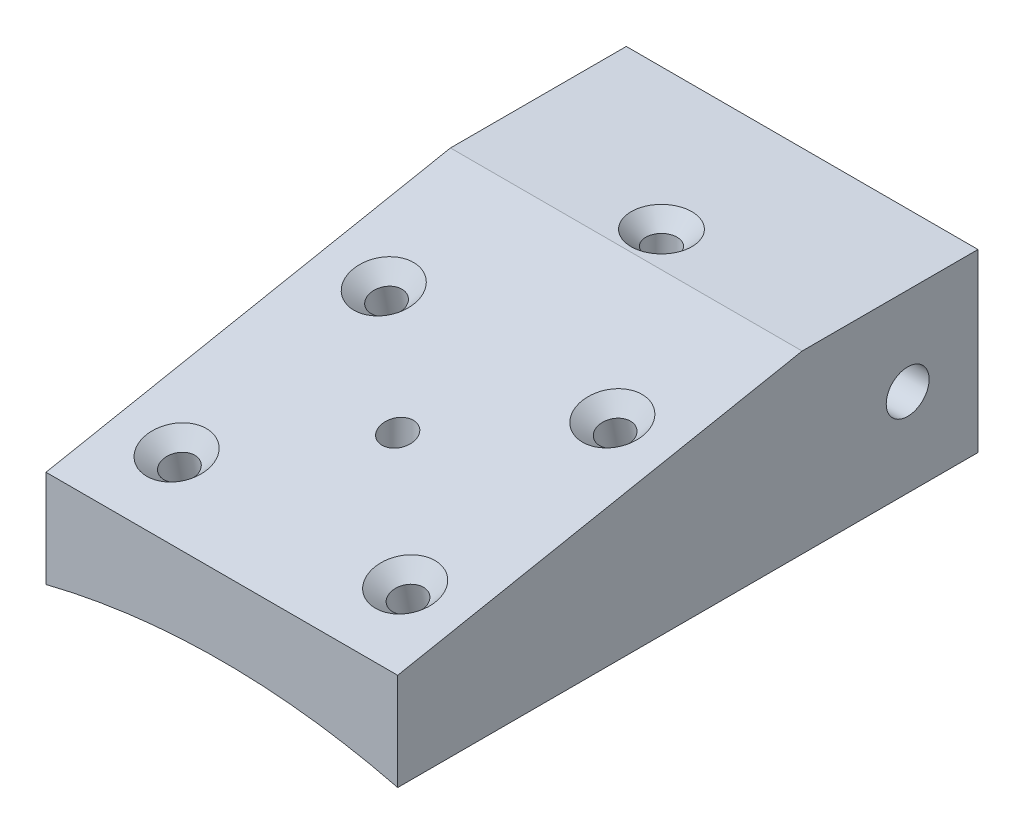
from build123d import *

# Parameters (mm, degrees)
BOSS_EXTRUDE1_DEPTH             = 11.5
F_2_56_TAPPED_HOLE3_D           = 1.778
F_2_56_TAPPED_HOLE3_CSINK_D     = 3.4544
F_2_56_TAPPED_HOLE3_CSINK_ANGLE = 90
CUT_EXTRUDE1_DEPTH              = 10
F_2_56_TAPPED_HOLE1_D           = 1.778
F_2_56_TAPPED_HOLE1_CSINK_D     = 3.4544
F_2_56_TAPPED_HOLE1_CSINK_ANGLE = 90
BOSS_EXTRUDE2_DEPTH             = 10
F_2_56_TAPPED_HOLE4_D           = 1.778
F_2_56_TAPPED_HOLE4_CSINK_D     = 3.4544
F_2_56_TAPPED_HOLE4_CSINK_ANGLE = 90
F_2_CLEARANCE_HOLE1_D           = 2.4384


with BuildPart() as part:
    # Sketch1 → Boss-Extrude1 (new body, symmetric)
    with BuildSketch(Plane.XY):
        with BuildLine():
            Line((-10, 39.778288752), (-10, 51.016))
            Line((-10, 51.016), (10, 51.016))
            Line((10, 51.016), (10, 39.778288752))
            ThreePointArc((10, 39.778288752), (0, 41.016), (-10, 39.778288752))
        make_face()
    extrude(amount=BOSS_EXTRUDE1_DEPTH, both=True)

    # #2-56 Tapped Hole3 (through all)
    with Locations(Plane(origin=(0, 51.016, 0), x_dir=(1, 0, 0), z_dir=(0, 1, 0))):
        with Locations((0, -1.5)):
            CounterSinkHole(F_2_56_TAPPED_HOLE3_D / 2, F_2_56_TAPPED_HOLE3_CSINK_D / 2, counter_sink_angle=F_2_56_TAPPED_HOLE3_CSINK_ANGLE)

    # Sketch2 → Cut-Extrude1 (cut, symmetric)
    with BuildSketch(Plane(origin=(0, 0, 0), x_dir=(0, 0, -1), z_dir=(1, 0, 0))):
        Polygon((-11.5, 45.307541641), (11.5, 49.778288752), (11.5, 51.016), (-11.5, 51.016), align=None)
    extrude(amount=CUT_EXTRUDE1_DEPTH, both=True, mode=Mode.SUBTRACT)

    # #2-56 Tapped Hole1 (through all)
    with Locations(Plane(origin=(0, 45.811969283, 8.904944751), x_dir=(1, 0, 0), z_dir=(0, 0.981627183, 0.190808995))):
        with Locations((6.5, 1.356373894), (6.5, 13.356373894), (-6.5, 13.356373894), (-6.5, 1.356373894)):
            CounterSinkHole(F_2_56_TAPPED_HOLE1_D / 2, F_2_56_TAPPED_HOLE1_CSINK_D / 2, counter_sink_angle=F_2_56_TAPPED_HOLE1_CSINK_ANGLE)

    # Sketch5 → Boss-Extrude2 (add)
    with BuildSketch(Plane(origin=(0, 0, -11.5), x_dir=(-1, 0, 0), z_dir=(0, 0, -1))):
        with BuildLine():
            Line((10, 39.778288752), (10, 49.778288752))
            Line((10, 49.778288752), (-10, 49.778288752))
            Line((-10, 49.778288752), (-10, 39.778288752))
            ThreePointArc((-10, 39.778288752), (0, 41.016), (10, 39.778288752))
        make_face()
    extrude(amount=BOSS_EXTRUDE2_DEPTH)

    # #2-56 Tapped Hole4 (through all)
    with Locations(Plane(origin=(0, 49.778288752, 0), x_dir=(1, 0, 0), z_dir=(0, 1, 0))):
        with Locations((0, 13.5)):
            CounterSinkHole(F_2_56_TAPPED_HOLE4_D / 2, F_2_56_TAPPED_HOLE4_CSINK_D / 2, counter_sink_angle=F_2_56_TAPPED_HOLE4_CSINK_ANGLE)

    # #2 Clearance Hole1 (through all)
    with Locations(Plane.ZY.offset(10)):
        with Locations((-17.5, 44.778288752)):
            Hole(F_2_CLEARANCE_HOLE1_D / 2)


solid = part.part
